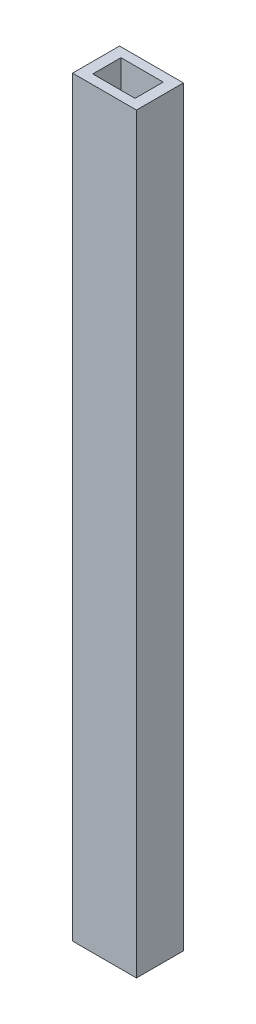
from build123d import *

# Parameters (mm, degrees)
SKETCH1_W           = 17.272
SKETCH1_H           = 12.7
SKETCH1_W_2         = 11.43
SKETCH1_H_2         = 7.62
BOSS_EXTRUDE1_DEPTH = 203.2


with BuildPart() as part:
    # Sketch1 → Boss-Extrude1 (new body)
    with BuildSketch(Plane(origin=(0, 0, 0), x_dir=(1, 0, 0), z_dir=(0, 1, 0))):
        with Locations((8.636, 6.35)):
            Rectangle(SKETCH1_W, SKETCH1_H)
        with Locations((8.636, 6.35)):
            Rectangle(SKETCH1_W_2, SKETCH1_H_2, mode=Mode.SUBTRACT)
    extrude(amount=BOSS_EXTRUDE1_DEPTH)


solid = part.part
